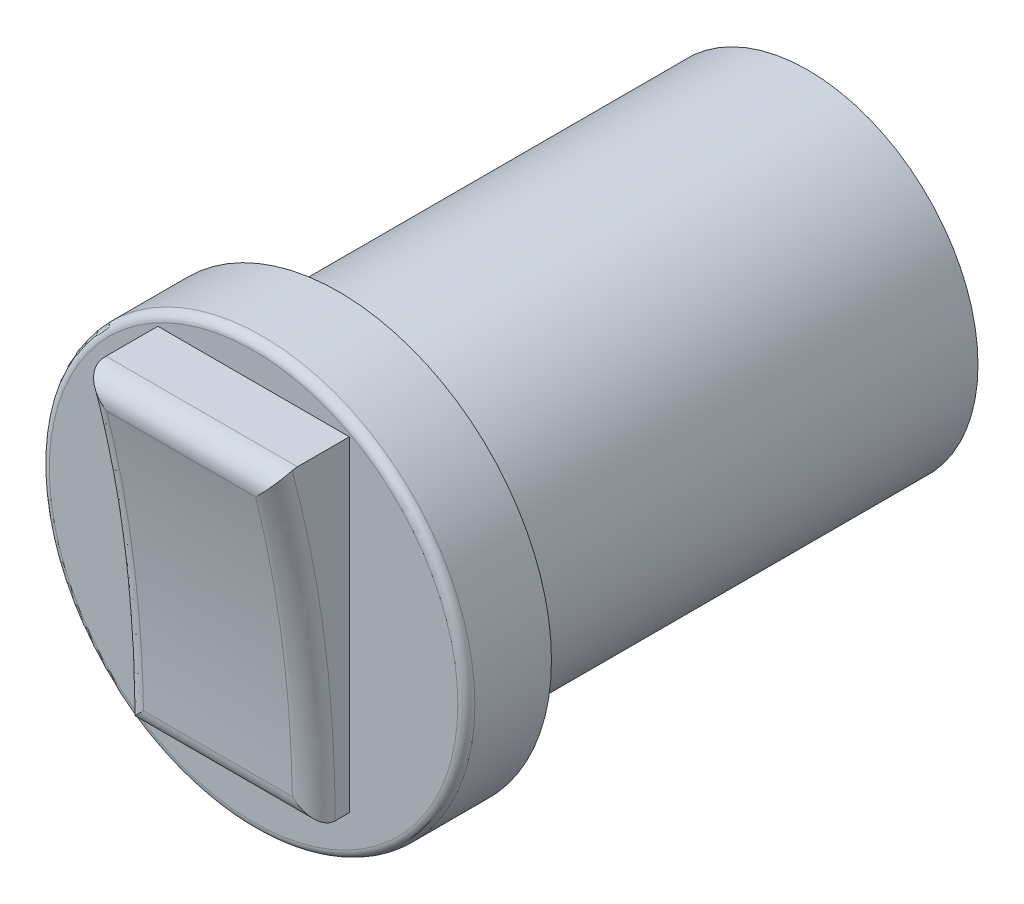
from build123d import *

# Parameters (mm, degrees)
SKETCH1_R           = 10.16
BOSS_EXTRUDE1_DEPTH = 28
SKETCH2_R           = 12.7
BOSS_EXTRUDE2_DEPTH = 5.08
BOSS_EXTRUDE3_DEPTH = 5.715
FILLET1_R           = 1.27
FILLET2_R           = 0.508


with BuildPart() as part:
    # Sketch1 → Boss-Extrude1 (new body)
    with BuildSketch(Plane.XY):
        Circle(SKETCH1_R)
    extrude(amount=BOSS_EXTRUDE1_DEPTH)

    # Sketch2 → Boss-Extrude2 (add)
    with BuildSketch(Plane.XY.offset(28)):
        Circle(SKETCH2_R)
    extrude(amount=BOSS_EXTRUDE2_DEPTH)

    # Sketch3 → Boss-Extrude3 (add, symmetric)
    with BuildSketch(Plane(origin=(0, 0, 0), x_dir=(0, 0, -1), z_dir=(1, 0, 0))):
        with BuildLine():
            Line((-33.08, -8.833721506), (-33.08, 10.59406456))
            Line((-33.08, 10.59406456), (-37.824147833, 10.59406456))
            add(Edge.make_bspline(
                [(-37.824147833, 10.59406456), (-35.198663917, 1.074784021), (-35.199636371, -8.833721506)],
                knots=[0, 0, 0, 1, 1, 1], degree=2))
            Line((-35.199636371, -8.833721506), (-33.08, -8.833721506))
        make_face()
    extrude(amount=BOSS_EXTRUDE3_DEPTH, both=True)

    # Fillet1
    fillet1_edges = [part.edges().sort_by_distance(p)[0] for p in [
        (-2.8575, -8.833721506, 35.199636371),
        (-5.715, 0.969066451, 35.854142221),
        (-2.8575, 10.59406456, 37.824147833),
        (5.715, 0.969066451, 35.854142221),
    ]]
    fillet(fillet1_edges, radius=FILLET1_R)

    # Fillet2
    fillet2_edges = [part.edges().sort_by_distance(p)[0] for p in [
        (-12.7, 0, 33.08),
    ]]
    fillet(fillet2_edges, radius=FILLET2_R)


solid = part.part
